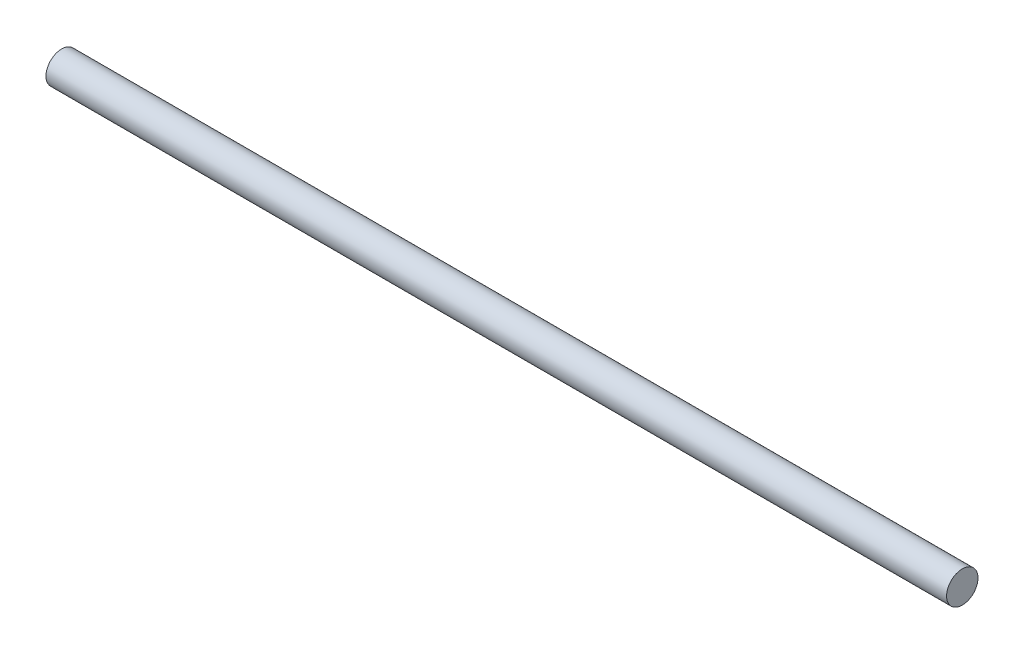
from build123d import *

# Parameters (mm, degrees)
SKETCH1_R           = 5
BOSS_EXTRUDE1_DEPTH = 143.3


with BuildPart() as part:
    # Sketch1 → Boss-Extrude1 (new body, symmetric)
    with BuildSketch(Plane(origin=(0, 0, 0), x_dir=(0, 0, -1), z_dir=(1, 0, 0))):
        Circle(SKETCH1_R)
    extrude(amount=BOSS_EXTRUDE1_DEPTH, both=True)


solid = part.part
